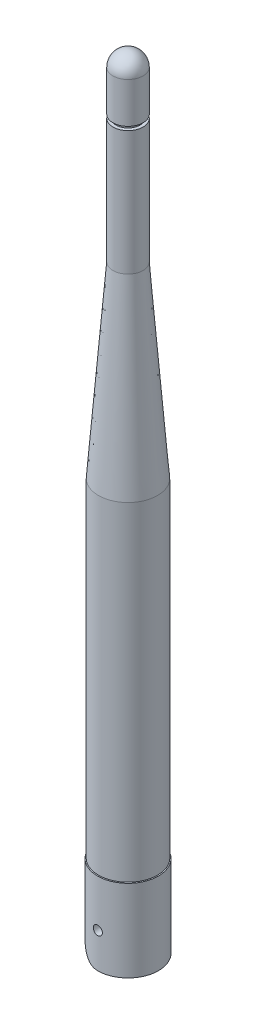
from build123d import *

# Parameters (mm, degrees)
SKETCH3_R               = 6.73735
BOSS_EXTRUDE1_DEPTH     = 18.1483
SKETCH1_R               = 1
CUT_EXTRUDE1_DEPTH      = 7.73735
CUT_EXTRUDE1_DEPTH_BACK = 7.73735
SKETCH2_W               = 8.8773
SKETCH2_H               = 13.7033
CUT_EXTRUDE2_DEPTH      = 10.9347
SKETCH4_W               = 8.3947
SKETCH4_H               = 8.3947
CUT_EXTRUDE3_DEPTH      = 19.1483001
CUT_EXTRUDE3_DEPTH_BACK = 1.0000001
CUT_EXTRUDE4_DEPTH      = 7.737350116
CUT_EXTRUDE4_DEPTH_BACK = 7.737350116
CUT_EXTRUDE5_DEPTH      = 7.737350116
CUT_EXTRUDE5_DEPTH_BACK = 7.737350116


with BuildPart() as part:
    # Sketch3 → Boss-Extrude1 (new body)
    with BuildSketch(Plane(origin=(0, 0, 0), x_dir=(1, 0, 0), z_dir=(0, 1, 0))):
        with Locations((6.73735, 0)):
            Circle(SKETCH3_R)
    extrude(amount=BOSS_EXTRUDE1_DEPTH)

    # Sketch1 → Cut-Extrude1 (cut, two sides)
    with BuildSketch(Plane.XY) as cut_extrude1_sk:
        with Locations((6.73735, 7.747)):
            Circle(SKETCH1_R)
    extrude(amount=CUT_EXTRUDE1_DEPTH, mode=Mode.SUBTRACT)
    extrude(cut_extrude1_sk.sketch, amount=-CUT_EXTRUDE1_DEPTH_BACK, mode=Mode.SUBTRACT)

    # Sketch2 → Cut-Extrude2 (cut)
    with BuildSketch(Plane(origin=(0, 0, 0), x_dir=(0, 0, -1), z_dir=(1, 0, 0))):
        with Locations((0, 6.85165)):
            Rectangle(SKETCH2_W, SKETCH2_H)
    extrude(amount=CUT_EXTRUDE2_DEPTH, mode=Mode.SUBTRACT)

    # Sketch4 → Cut-Extrude3 (cut, two sides)
    with BuildSketch(Plane(origin=(0, 0, 0), x_dir=(1, 0, 0), z_dir=(0, 1, 0))) as cut_extrude3_sk:
        with Locations((6.73735, 0)):
            Rectangle(SKETCH4_W, SKETCH4_H)
    extrude(amount=CUT_EXTRUDE3_DEPTH, mode=Mode.SUBTRACT)
    extrude(cut_extrude3_sk.sketch, amount=-CUT_EXTRUDE3_DEPTH_BACK, mode=Mode.SUBTRACT)

    # Sketch6 → Cut-Extrude4 (cut, two sides)
    with BuildSketch(Plane.XY) as cut_extrude4_sk:
        Polygon((1.6891, 13.7033), (0, 16.2433), (0, 13.7033), align=None)
    extrude(amount=CUT_EXTRUDE4_DEPTH, mode=Mode.SUBTRACT)
    extrude(cut_extrude4_sk.sketch, amount=-CUT_EXTRUDE4_DEPTH_BACK, mode=Mode.SUBTRACT)

    # Sketch7 → Cut-Extrude5 (cut, two sides)
    with BuildSketch(Plane.XY) as cut_extrude5_sk:
        with BuildLine():
            Line((1.6688054, 5.0685446), (1.6688054, 0))
            Line((1.6688054, 0), (6.73735, 0))
            ThreePointArc((6.73735, 0), (3.153347743, 1.484542343), (1.6688054, 5.0685446))
        make_face()
    extrude(amount=CUT_EXTRUDE5_DEPTH, mode=Mode.SUBTRACT)
    extrude(cut_extrude5_sk.sketch, amount=-CUT_EXTRUDE5_DEPTH_BACK, mode=Mode.SUBTRACT)


with BuildPart() as body_2:
    # Sketch5 → Revolve1 (revolve)
    with BuildSketch(Plane.XY):
        with BuildLine():
            Line((13.27785, 18.2245), (13.27785, 90.9955))
            Line((13.27785, 90.9955), (10.0711, 132.5083))
            Line((10.0711, 132.5083), (10.0711, 160.0165))
            Line((10.0711, 160.0165), (9.36625, 160.0165))
            Line((9.36625, 160.0165), (9.36625, 160.8293))
            Line((9.36625, 160.8293), (10.0711, 160.8293))
            Line((10.0711, 160.8293), (10.0711, 169.81455))
            ThreePointArc((10.0711, 169.81455), (9.094667232, 172.171867232), (6.73735, 173.1483))
            Line((6.73735, 173.1483), (6.73735, 169.81455))
            Line((6.73735, 169.81455), (8.1661, 169.81455))
            Line((8.1661, 169.81455), (8.1661, 18.2245))
            Line((8.1661, 18.2245), (13.27785, 18.2245))
        make_face()
    revolve(axis=Axis((6.73735, 18.1483, 0), (0, 1, 0)))


solid = Compound([part.part, body_2.part])
